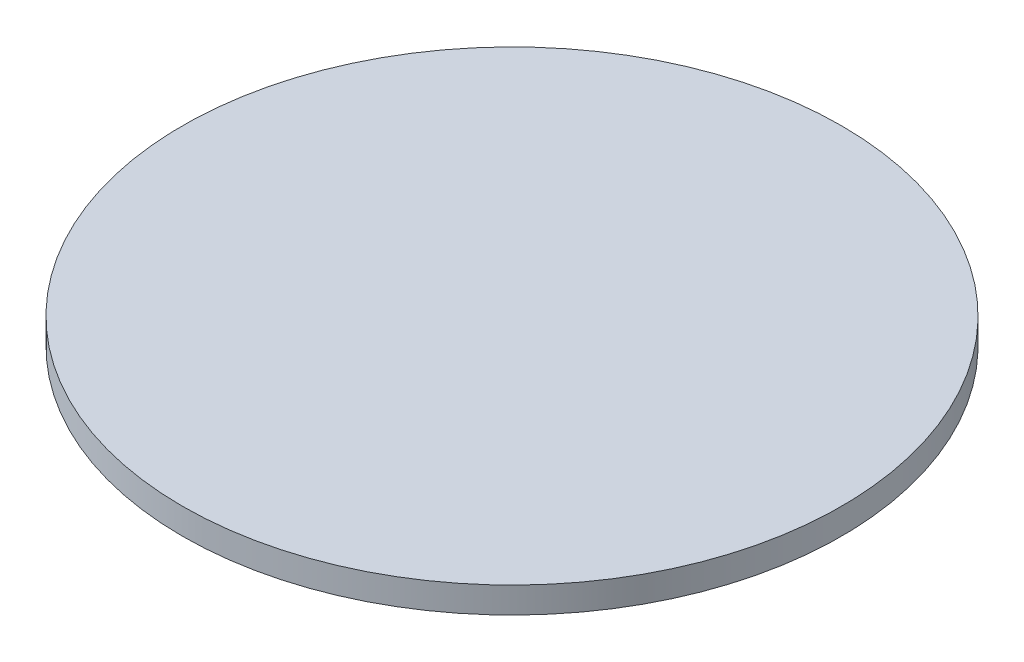
from build123d import *

# Parameters (mm, degrees)
SKETCH1_R           = 25.4508
BOSS_EXTRUDE1_DEPTH = 2.0066


with BuildPart() as part:
    # Sketch1 → Boss-Extrude1 (new body)
    with BuildSketch(Plane(origin=(0, 0, 0), x_dir=(1, 0, 0), z_dir=(0, 1, 0))):
        Circle(SKETCH1_R)
    extrude(amount=BOSS_EXTRUDE1_DEPTH)


solid = part.part
